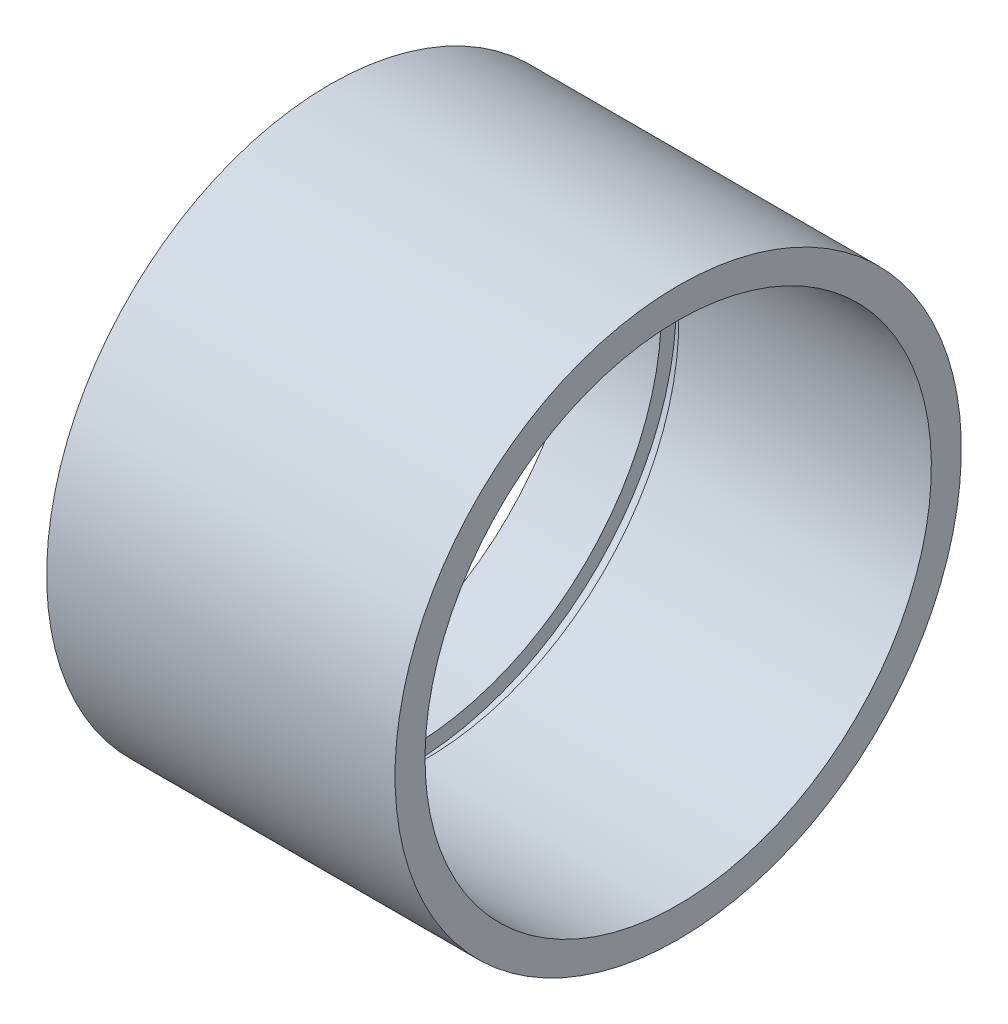
from build123d import *

# Parameters (mm, degrees)
SWEEP1_PITCH       = 0.704426667
SWEEP1_HEIGHT      = 1.3208
SWEEP1_RADIUS      = 28.5496
SWEEP1_START_ANGLE = 180
SKETCH3_W          = 0.6604
SKETCH3_H          = 5.08
CUT_EXTRUDE4_DEPTH = 0.682414
CUT_EXTRUDE3_DEPTH = 0.682398


with BuildPart() as part:
    # Sweep1: sweep along a helix
    with BuildLine() as sweep1_path:
        add(Helix(SWEEP1_PITCH, SWEEP1_HEIGHT, SWEEP1_RADIUS, center=(0, 0, 0), direction=(1, 0, 0), mode=Mode.PRIVATE).rotate(Axis((0, 0, 0), (1, 0, 0)), SWEEP1_START_ANGLE))
    # Sketch3 → Sweep1 (sweep)
    with BuildSketch(Plane(origin=(0, 0, 0), x_dir=(1, 0, 0), z_dir=(0, 1, 0))):
        with Locations((0.3302, 31.0896)):
            Rectangle(SKETCH3_W, SKETCH3_H)
    sweep(path=sweep1_path.line, is_frenet=True)

    # Sketch8 → Cut-Extrude4 (cut)
    with BuildSketch(Plane(origin=(0, 0, 0), x_dir=(0, 0, -1), z_dir=(1, 0, 0))):
        with BuildLine():
            Line((30.242933333, 0), (33.6296, 0))
            ThreePointArc((33.6296, 0), (33.118690811, 5.839718756), (31.60148696, 11.502000612))
            ThreePointArc((31.60148696, 11.502000612), (30.583748126, 5.790977595), (30.242933333, 0))
        make_face()
    extrude(amount=CUT_EXTRUDE4_DEPTH, mode=Mode.SUBTRACT)

    # Sketch7 → Cut-Extrude3 (cut)
    with BuildSketch(Plane(origin=(1.980679935, 0, 0), x_dir=(0, 0, -1), z_dir=(1, 0, 0))):
        with BuildLine():
            Line((21.384984059, -21.384982427), (23.779719052, -23.779717365))
            ThreePointArc((23.779719052, -23.779717365), (19.289146911, -27.547755038), (14.212483755, -30.478768047))
            ThreePointArc((14.212483755, -30.478768047), (17.531136878, -25.720814646), (21.384984059, -21.384982427))
        make_face()
    extrude(amount=-CUT_EXTRUDE3_DEPTH, mode=Mode.SUBTRACT)


with BuildPart() as body_2:
    # Sketch2 → Revolve1 (revolve)
    with BuildSketch(Plane.XY):
        Polygon((-9.931660032, -31.75), (-9.931660032, -35.5092), (33.756339968, -35.5092), (33.756339968, -31.75), (2.082539968, -31.75), (2.082539968, -33.6296), (-0.101860032, -33.6296), (-0.101860032, -31.75), align=None)
    revolve(axis=Axis((33.756339968, 0, 0), (-1, 0, 0)))


solid = body_2.part
